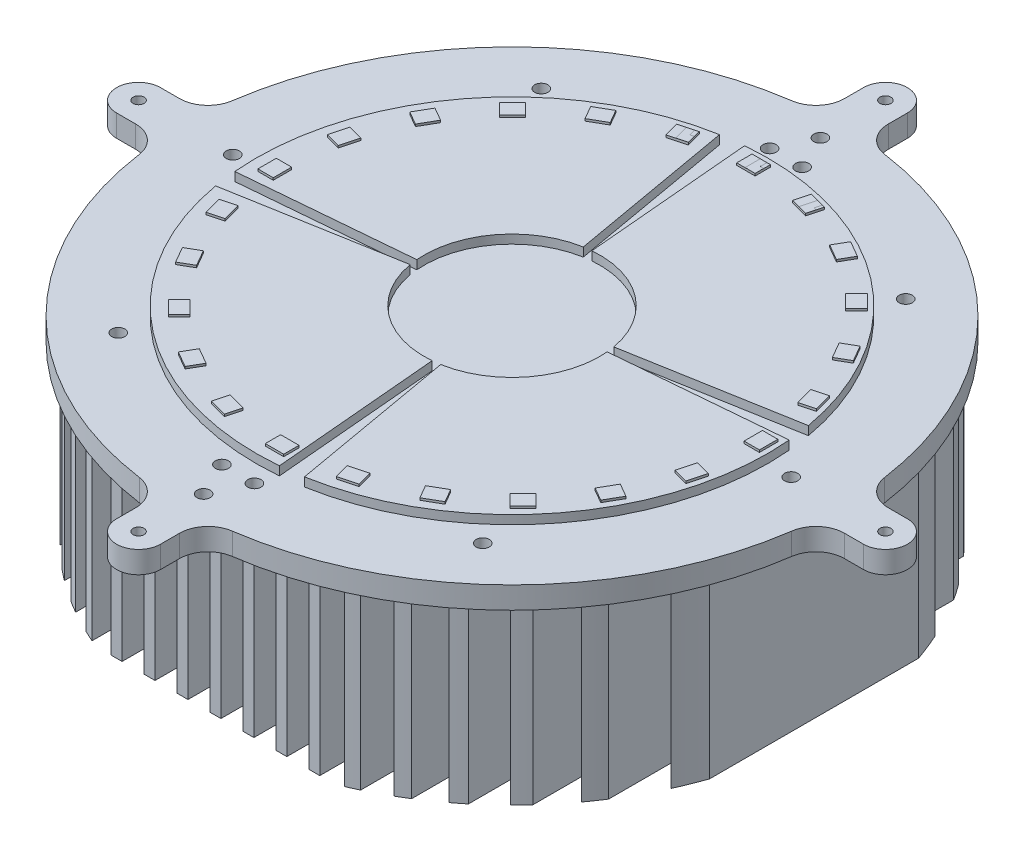
from build123d import *

# Parameters (mm, degrees)
SKETCH3_R           = 2.5
BOSS_EXTRUDE4_DEPTH = 10
SKETCH4_W           = 5
SKETCH4_H           = 270
BOSS_EXTRUDE5_DEPTH = 80
BOSS_EXTRUDE7_DEPTH = 4
BOSS_EXTRUDE6_DEPTH = 1
SKETCH7_R           = 3
CUT_EXTRUDE1_DEPTH  = 10
BOSS_EXTRUDE8_DEPTH = 0.01


with BuildPart() as part:
    # Sketch3 → Boss-Extrude4 (new body)
    with BuildSketch(Plane(origin=(0, 0, 0), x_dir=(1, 0, 0), z_dir=(0, 1, 0))):
        with BuildLine():
            Line((161.369142032, 10), (170, 10))
            ThreePointArc((170, 10), (180, 0), (170, -10))
            Line((170, -10), (161.369142032, -10))
            ThreePointArc((161.369142032, -10), (152.849946816, -13.180462695), (148.499210458, -21.165644172))
            ThreePointArc((148.499210458, -21.165644172), (106.066017178, -106.066017178), (21.165644172, -148.499210458))
            ThreePointArc((21.165644172, -148.499210458), (13.180462695, -152.849946816), (10, -161.369142032))
            Line((10, -161.369142032), (10, -170))
            ThreePointArc((10, -170), (0, -180), (-10, -170))
            Line((-10, -170), (-10, -161.369142032))
            ThreePointArc((-10, -161.369142032), (-13.180462695, -152.849946816), (-21.165644172, -148.499210458))
            ThreePointArc((-21.165644172, -148.499210458), (-106.066017178, -106.066017178), (-148.499210458, -21.165644172))
            ThreePointArc((-148.499210458, -21.165644172), (-152.849946816, -13.180462695), (-161.369142032, -10))
            Line((-161.369142032, -10), (-170, -10))
            ThreePointArc((-170, -10), (-180, 0), (-170, 10))
            Line((-170, 10), (-161.369142032, 10))
            ThreePointArc((-161.369142032, 10), (-152.849946816, 13.180462695), (-148.499210458, 21.165644172))
            ThreePointArc((-148.499210458, 21.165644172), (-106.066017178, 106.066017178), (-21.165644172, 148.499210458))
            ThreePointArc((-21.165644172, 148.499210458), (-13.180462695, 152.849946816), (-10, 161.369142032))
            Line((-10, 161.369142032), (-10, 170))
            ThreePointArc((-10, 170), (0, 180), (10, 170))
            Line((10, 170), (10, 161.369142032))
            ThreePointArc((10, 161.369142032), (13.180462695, 152.849946816), (21.165644172, 148.499210458))
            ThreePointArc((21.165644172, 148.499210458), (106.066017178, 106.066017178), (148.499210458, 21.165644172))
            ThreePointArc((148.499210458, 21.165644172), (152.849946816, 13.180462695), (161.369142032, 10))
        make_face()
        with Locations((0, 170)):
            Circle(SKETCH3_R, mode=Mode.SUBTRACT)
        with Locations((170, 0)):
            Circle(SKETCH3_R, mode=Mode.SUBTRACT)
        with Locations((0, -170)):
            Circle(SKETCH3_R, mode=Mode.SUBTRACT)
        with Locations((-170, 0)):
            Circle(SKETCH3_R, mode=Mode.SUBTRACT)
    extrude(amount=-BOSS_EXTRUDE4_DEPTH)

    # Sketch4 → Boss-Extrude5 (add)
    with BuildSketch(Plane.XZ.offset(10)):
        Rectangle(SKETCH4_W, SKETCH4_H)
        with Locations((15, 0)):
            Rectangle(SKETCH4_W, SKETCH4_H)
        with Locations((30, 0)):
            Rectangle(SKETCH4_W, SKETCH4_H)
        with Locations((45, 0)):
            Rectangle(SKETCH4_W, SKETCH4_H)
        with BuildLine():
            Line((57.5, -133.656275573), (57.5, 133.656275573))
            ThreePointArc((57.5, 133.656275573), (60.010675074, 132.547987073), (62.5, 131.392541645))
            Line((62.5, 131.392541645), (62.5, -131.392541645))
            ThreePointArc((62.5, -131.392541645), (60.010675074, -132.547987073), (57.5, -133.656275573))
        make_face()
        with BuildLine():
            Line((72.5, -126.150703526), (72.5, 126.150703526))
            ThreePointArc((72.5, 126.150703526), (75.015083697, 124.671517268), (77.5, 123.142194231))
            Line((77.5, 123.142194231), (77.5, -123.142194231))
            ThreePointArc((77.5, -123.142194231), (75.015083697, -124.671517268), (72.5, -126.150703526))
        make_face()
        with BuildLine():
            Line((87.5, -116.249731182), (87.5, 116.249731182))
            ThreePointArc((87.5, 116.249731182), (90.021532442, 114.308239846), (92.5, 112.312065247))
            Line((92.5, 112.312065247), (92.5, -112.312065247))
            ThreePointArc((92.5, -112.312065247), (90.021532442, -114.308239846), (87.5, -116.249731182))
        make_face()
        with BuildLine():
            Line((102.5, -103.266645147), (102.5, 103.266645147))
            ThreePointArc((102.5, 103.266645147), (105.032379388, 100.689866819), (107.5, 98.051007134))
            Line((107.5, 98.051007134), (107.5, -98.051007134))
            ThreePointArc((107.5, -98.051007134), (105.032379388, -100.689866819), (102.5, -103.266645147))
        make_face()
        with BuildLine():
            Line((117.5, -85.813751812), (117.5, 85.813751812))
            ThreePointArc((117.5, 85.813751812), (120.055537207, 82.200474366), (122.5, 78.511145706))
            Line((122.5, 78.511145706), (122.5, -78.511145706))
            ThreePointArc((122.5, -78.511145706), (120.055537207, -82.200474366), (117.5, -85.813751812))
        make_face()
        with BuildLine():
            Line((132.5, -60.116553461), (132.5, 60.116553461))
            ThreePointArc((132.5, 60.116553461), (135.145409966, 53.907032613), (137.5, 47.581509013))
            Line((137.5, 47.581509013), (137.5, -47.581509013))
            ThreePointArc((137.5, -47.581509013), (135.145409966, -53.907032613), (132.5, -60.116553461))
        make_face()
        with Locations((-15, 0)):
            Rectangle(SKETCH4_W, SKETCH4_H)
        with Locations((-30, 0)):
            Rectangle(SKETCH4_W, SKETCH4_H)
        with Locations((-45, 0)):
            Rectangle(SKETCH4_W, SKETCH4_H)
        with BuildLine():
            Line((-57.5, -133.656275573), (-57.5, 133.656275573))
            ThreePointArc((-57.5, 133.656275573), (-60.010675074, 132.547987073), (-62.5, 131.392541645))
            Line((-62.5, 131.392541645), (-62.5, -131.392541645))
            ThreePointArc((-62.5, -131.392541645), (-60.010675074, -132.547987073), (-57.5, -133.656275573))
        make_face()
        with BuildLine():
            Line((-72.5, -126.150703526), (-72.5, 126.150703526))
            ThreePointArc((-72.5, 126.150703526), (-75.015083697, 124.671517268), (-77.5, 123.142194231))
            Line((-77.5, 123.142194231), (-77.5, -123.142194231))
            ThreePointArc((-77.5, -123.142194231), (-75.015083697, -124.671517268), (-72.5, -126.150703526))
        make_face()
        with BuildLine():
            Line((-87.5, -116.249731182), (-87.5, 116.249731182))
            ThreePointArc((-87.5, 116.249731182), (-90.021532442, 114.308239846), (-92.5, 112.312065247))
            Line((-92.5, 112.312065247), (-92.5, -112.312065247))
            ThreePointArc((-92.5, -112.312065247), (-90.021532442, -114.308239846), (-87.5, -116.249731182))
        make_face()
        with BuildLine():
            Line((-102.5, -103.266645147), (-102.5, 103.266645147))
            ThreePointArc((-102.5, 103.266645147), (-105.032379388, 100.689866819), (-107.5, 98.051007134))
            Line((-107.5, 98.051007134), (-107.5, -98.051007134))
            ThreePointArc((-107.5, -98.051007134), (-105.032379388, -100.689866819), (-102.5, -103.266645147))
        make_face()
        with BuildLine():
            Line((-117.5, -85.813751812), (-117.5, 85.813751812))
            ThreePointArc((-117.5, 85.813751812), (-120.055537207, 82.200474366), (-122.5, 78.511145706))
            Line((-122.5, 78.511145706), (-122.5, -78.511145706))
            ThreePointArc((-122.5, -78.511145706), (-120.055537207, -82.200474366), (-117.5, -85.813751812))
        make_face()
        with BuildLine():
            Line((-132.5, -60.116553461), (-132.5, 60.116553461))
            ThreePointArc((-132.5, 60.116553461), (-135.145409966, 53.907032613), (-137.5, 47.581509013))
            Line((-137.5, 47.581509013), (-137.5, -47.581509013))
            ThreePointArc((-137.5, -47.581509013), (-135.145409966, -53.907032613), (-132.5, -60.116553461))
        make_face()
    extrude(amount=BOSS_EXTRUDE5_DEPTH)

    # Sketch8 → Boss-Extrude7 (add)
    with BuildSketch(Plane(origin=(0, 0, 0), x_dir=(1, 0, 0), z_dir=(0, 1, 0))):
        with BuildLine():
            Line((3.48622971, -39.847787924), (10.151210742, -116.028869713))
            ThreePointArc((10.151210742, -116.028869713), (-70.903710558, -92.403514628), (-114.702608522, -20.22516464))
            Line((-114.702608522, -20.22516464), (-39.39231012, -6.945927107))
            ThreePointArc((-39.39231012, -6.945927107), (-24.35045716, -31.734133612), (3.48622971, -39.847787924))
        make_face()
        with BuildLine():
            Line((-39.847787924, -3.48622971), (-116.028869713, -10.151210742))
            ThreePointArc((-116.028869713, -10.151210742), (-92.403514628, 70.903710558), (-20.22516464, 114.702608522))
            Line((-20.22516464, 114.702608522), (-6.945927107, 39.39231012))
            ThreePointArc((-6.945927107, 39.39231012), (-31.734133612, 24.35045716), (-39.847787924, -3.48622971))
        make_face()
        with BuildLine():
            Line((-3.48622971, 39.847787924), (-10.151210742, 116.028869713))
            ThreePointArc((-10.151210742, 116.028869713), (70.903710558, 92.403514628), (114.702608522, 20.22516464))
            Line((114.702608522, 20.22516464), (39.39231012, 6.945927107))
            ThreePointArc((39.39231012, 6.945927107), (24.35045716, 31.734133612), (-3.48622971, 39.847787924))
        make_face()
        with BuildLine():
            Line((39.847787924, 3.48622971), (116.028869713, 10.151210742))
            ThreePointArc((116.028869713, 10.151210742), (92.403514628, -70.903710558), (20.22516464, -114.702608522))
            Line((20.22516464, -114.702608522), (6.945927107, -39.39231012))
            ThreePointArc((6.945927107, -39.39231012), (31.734133612, -24.35045716), (39.847787924, 3.48622971))
        make_face()
    extrude(amount=BOSS_EXTRUDE7_DEPTH)

    # Sketch5 → Boss-Extrude6 (add)
    with BuildSketch(Plane(origin=(0, 4, 0), x_dir=(1, 0, 0), z_dir=(0, 1, 0))):
        Polygon((0, 113.458572259), (4.19, 113.458572259), (4.19, 106.478572259), (0, 106.478572259), (-4.19, 106.478572259), (-4.19, 113.458572259), align=None)
        Polygon((23.312466941, 104.403404118), (25.119023876, 111.145566386), (29.166253088, 110.061114587), (33.2134823, 108.976662788), (31.406925365, 102.23450052), (27.359696153, 103.318952319), align=None)
        Polygon((49.340717009, 95.280783385), (52.830717009, 101.325640704), (56.459363451, 99.230640704), (60.088009893, 97.135640704), (56.598009893, 91.090783385), (52.969363451, 93.185783385), align=None)
        Polygon((72.120967976, 79.732401588), (77.056573309, 84.66800692), (80.019350722, 81.705229507), (82.982128135, 78.742452094), (78.046522803, 73.806846761), (75.08374539, 76.769624174), align=None)
        Polygon((90.100783385, 58.81785525), (96.145640704, 62.30785525), (98.240640704, 58.679208808), (100.335640704, 55.050562366), (94.290783385, 51.560562366), (92.195783385, 55.189208808), align=None)
        Polygon((102.054868529, 33.962436142), (108.797030796, 35.768993076), (109.881482595, 31.721763864), (110.965934394, 27.674534652), (104.223772127, 25.867977717), (103.139320328, 29.915206929), align=None)
        Polygon((107.168572259, 6.86), (114.148572259, 6.86), (114.148572259, 2.67), (114.148572259, -1.52), (107.168572259, -1.52), (107.168572259, 2.67), align=None)
        Polygon((105.093404118, -20.642466941), (111.835566386, -22.449023876), (110.751114587, -26.496253088), (109.666662788, -30.5434823), (102.92450052, -28.736925365), (104.008952319, -24.689696153), align=None)
        Polygon((95.970783385, -46.670717009), (102.015640704, -50.160717009), (99.920640704, -53.789363451), (97.825640704, -57.418009893), (91.780783385, -53.928009893), (93.875783385, -50.299363451), align=None)
        Polygon((80.422401588, -69.450967976), (85.35800692, -74.386573309), (82.395229507, -77.349350722), (79.432452094, -80.312128135), (74.496846761, -75.376522803), (77.459624174, -72.41374539), align=None)
        Polygon((59.50785525, -87.430783385), (62.99785525, -93.475640704), (59.369208808, -95.570640704), (55.740562366, -97.665640704), (52.250562366, -91.620783385), (55.879208808, -89.525783385), align=None)
        Polygon((34.652436142, -99.384868529), (36.458993076, -106.127030796), (32.411763864, -107.211482595), (28.364534652, -108.295934394), (26.557977717, -101.553772127), (30.605206929, -100.469320328), align=None)
        Polygon((7.55, -104.498572259), (7.55, -111.478572259), (3.36, -111.478572259), (-0.83, -111.478572259), (-0.83, -104.498572259), (3.36, -104.498572259), align=None)
        Polygon((-19.952466941, -102.423404118), (-21.759023876, -109.165566386), (-25.806253088, -108.081114587), (-29.8534823, -106.996662788), (-28.046925365, -100.25450052), (-23.999696153, -101.338952319), align=None)
        Polygon((-45.980717009, -93.300783385), (-49.470717009, -99.345640704), (-53.099363451, -97.250640704), (-56.728009893, -95.155640704), (-53.238009893, -89.110783385), (-49.609363451, -91.205783385), align=None)
        Polygon((-68.760967976, -77.752401588), (-73.696573309, -82.68800692), (-76.659350722, -79.725229507), (-79.622128135, -76.762452094), (-74.686522803, -71.826846761), (-71.72374539, -74.789624174), align=None)
        Polygon((-86.740783385, -56.83785525), (-92.785640704, -60.32785525), (-94.880640704, -56.699208808), (-96.975640704, -53.070562366), (-90.930783385, -49.580562366), (-88.835783385, -53.209208808), align=None)
        Polygon((-98.694868529, -31.982436142), (-105.437030796, -33.788993076), (-106.521482595, -29.741763864), (-107.605934394, -25.694534652), (-100.863772127, -23.887977717), (-99.779320328, -27.935206929), align=None)
        Polygon((-103.808572259, -4.88), (-110.788572259, -4.88), (-110.788572259, -0.69), (-110.788572259, 3.5), (-103.808572259, 3.5), (-103.808572259, -0.69), align=None)
        Polygon((-101.733404118, 22.622466941), (-108.475566386, 24.429023876), (-107.391114587, 28.476253088), (-106.306662788, 32.5234823), (-99.56450052, 30.716925365), (-100.648952319, 26.669696153), align=None)
        Polygon((-92.610783385, 48.650717009), (-98.655640704, 52.140717009), (-96.560640704, 55.769363451), (-94.465640704, 59.398009893), (-88.420783385, 55.908009893), (-90.515783385, 52.279363451), align=None)
        Polygon((-77.062401588, 71.430967976), (-81.99800692, 76.366573309), (-79.035229507, 79.329350722), (-76.072452094, 82.292128135), (-71.136846761, 77.356522803), (-74.099624174, 74.39374539), align=None)
        Polygon((-56.14785525, 89.410783385), (-59.63785525, 95.455640704), (-56.009208808, 97.550640704), (-52.380562366, 99.645640704), (-48.890562366, 93.600783385), (-52.519208808, 91.505783385), align=None)
        Polygon((-31.292436142, 101.364868529), (-33.098993076, 108.107030796), (-29.051763864, 109.191482595), (-25.004534652, 110.275934394), (-23.197977717, 103.533772127), (-27.245206929, 102.449320328), align=None)
    extrude(amount=BOSS_EXTRUDE6_DEPTH)

    # Sketch7 → Cut-Extrude1 (cut)
    with BuildSketch(Plane(origin=(0, 0, 0), x_dir=(1, 0, 0), z_dir=(0, 1, 0))):
        with Locations((-127.088241501, 0)):
            Circle(SKETCH7_R)
        with Locations((0, 140.377871213)):
            Circle(SKETCH7_R)
        with Locations((0, -140.377871213)):
            Circle(SKETCH7_R)
        with Locations((127.088241501, 0)):
            Circle(SKETCH7_R)
        with Locations((-67.712428911, 0)):
            Circle(SKETCH7_R)
        with Locations((-52.130916661, 49.662536464)):
            Circle(SKETCH7_R)
        with Locations((52.130916661, 49.662536464)):
            Circle(SKETCH7_R)
        with Locations((52.130916661, -49.662536464)):
            Circle(SKETCH7_R)
        with Locations((-52.130916661, -49.662536464)):
            Circle(SKETCH7_R)
        with Locations((67.712428911, 0)):
            Circle(SKETCH7_R)
        with Locations((-82.954299453, 96.280866896)):
            Circle(SKETCH7_R)
        with Locations((82.954299453, 96.280866896)):
            Circle(SKETCH7_R)
        with Locations((82.954299453, -96.280866896)):
            Circle(SKETCH7_R)
        with Locations((-82.954299453, -96.280866896)):
            Circle(SKETCH7_R)
        with Locations((7.399863504, -124.662387406)):
            Circle(SKETCH7_R)
        with Locations((-7.399863504, -124.662387406)):
            Circle(SKETCH7_R)
        with Locations((7.399863504, 124.662387406)):
            Circle(SKETCH7_R)
        with Locations((-7.399863504, 124.662387406)):
            Circle(SKETCH7_R)
    extrude(amount=-CUT_EXTRUDE1_DEPTH, mode=Mode.SUBTRACT)

    # Sketch10 → Boss-Extrude8 (add)
    with BuildSketch(Plane(origin=(0, 5, 0), x_dir=(1, 0, 0), z_dir=(0, 1, 0))):
        Polygon((2.625, 113.393572259), (2.625, 110.393572259), (4.125, 110.393572259), (4.125, 106.543572259), (-0.425, 106.543572259), (-0.425, 113.393572259), align=None)
        Polygon((31.211322058, 106.340018515), (32.357416748, 106.032923368), (31.360963425, 102.314108937), (27.268794964, 103.410602171), (29.041705423, 110.027194081), (31.987779193, 109.237795994), align=None)
        Polygon((-25.915134148, 106.858818502), (-24.274039458, 107.298548499), (-23.277586134, 103.579734067), (-27.864754595, 102.350605983), (-29.637665054, 108.967197893), (-26.691591283, 109.75659598), align=None)
    extrude(amount=BOSS_EXTRUDE8_DEPTH)


solid = part.part
